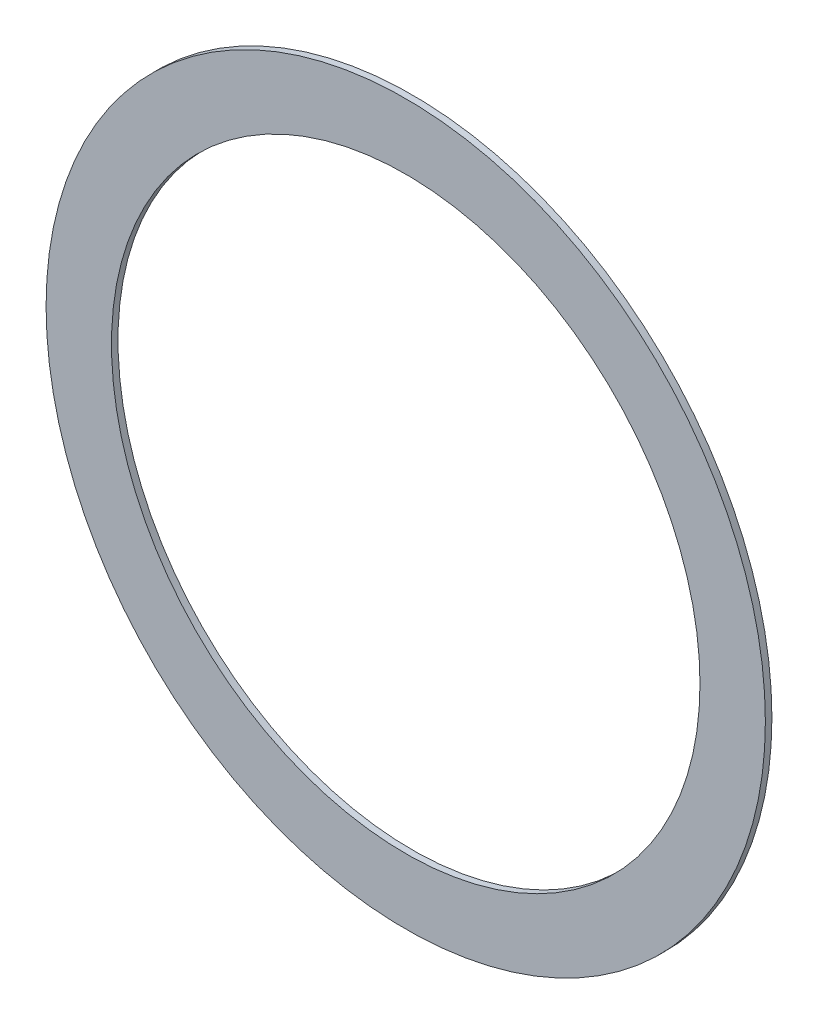
from build123d import *

# Parameters (mm, degrees)
SKETCH1_R           = 2.75
SKETCH1_R_2         = 2.25
BOSS_EXTRUDE1_DEPTH = 0.05


with BuildPart() as part:
    # Sketch1 → Boss-Extrude1 (new body)
    with BuildSketch(Plane.XY):
        Circle(SKETCH1_R)
        Circle(SKETCH1_R_2, mode=Mode.SUBTRACT)
    extrude(amount=BOSS_EXTRUDE1_DEPTH)


solid = part.part
